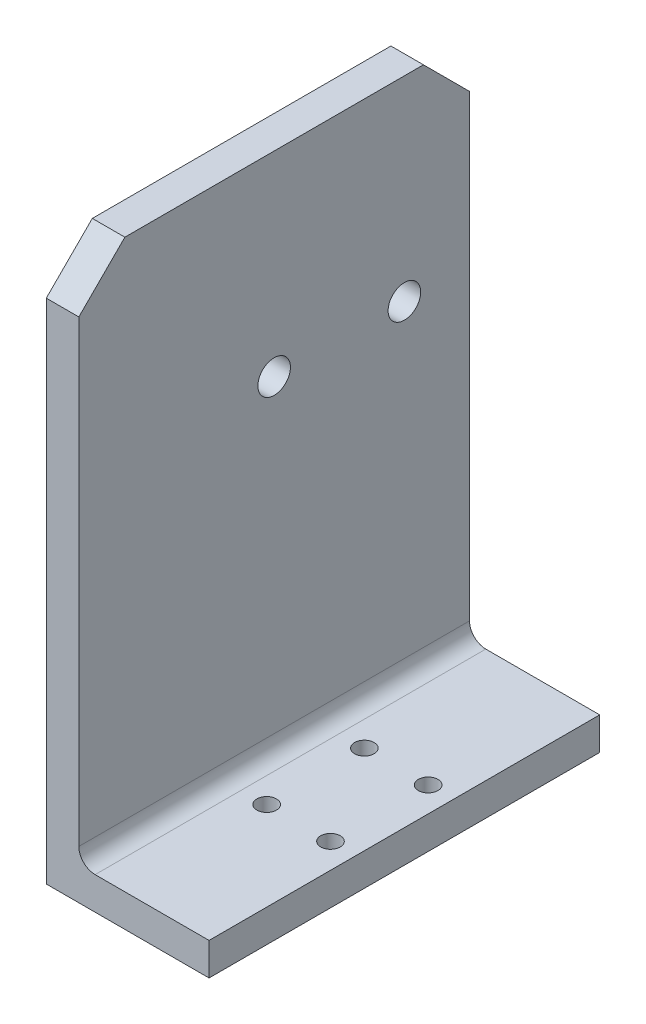
from build123d import *

# Parameters (mm, degrees)
SKETCH1_W             = 25
SKETCH1_H             = 60
BOSS_EXTRUDE1_DEPTH   = 5
SKETCH8_W             = 5
SKETCH8_H             = 60
BOSS_EXTRUDE2_DEPTH   = 80
SKETCH9_R             = 2.5
CUT_EXTRUDE1_DEPTH    = 5
CUT_EXTRUDE2_REACH    = 7
FILLET1_R             = 2.5
F_3_0MM_DOWEL_HOLE2_D = 3
SKETCH15_R            = 2.5
CUT_EXTRUDE3_DEPTH    = 6


with BuildPart() as part:
    # Sketch1 → Boss-Extrude1 (new body)
    with BuildSketch(Plane(origin=(0, 0, 0), x_dir=(1, 0, 0), z_dir=(0, 1, 0))):
        Rectangle(SKETCH1_W, SKETCH1_H)
    extrude(amount=BOSS_EXTRUDE1_DEPTH)

    # Sketch8 → Boss-Extrude2 (add)
    with BuildSketch(Plane(origin=(0, 5, 0), x_dir=(1, 0, 0), z_dir=(0, 1, 0))):
        with Locations((-10, 0)):
            Rectangle(SKETCH8_W, SKETCH8_H)
    extrude(amount=BOSS_EXTRUDE2_DEPTH)

    # Sketch9 → Cut-Extrude1 (cut)
    with BuildSketch(Plane(origin=(-7.5, 0, 0), x_dir=(0, 0, -1), z_dir=(1, 0, 0))):
        with Locations((0, 55)):
            Circle(SKETCH9_R)
    extrude(amount=-CUT_EXTRUDE1_DEPTH, mode=Mode.SUBTRACT)

    # Sketch10 → Cut-Extrude2 (cut, up to next)
    with BuildSketch(Plane(origin=(-7.5, 0, 0), x_dir=(0, 0, -1), z_dir=(1, 0, 0)), mode=Mode.PRIVATE) as cut_extrude2_sk1:
        Polygon((-30, 77.928932188), (-22.928932188, 85), (-30, 85), align=None)
    cut_extrude2_tool1 = extrude(cut_extrude2_sk1.sketch, amount=-CUT_EXTRUDE2_REACH, mode=Mode.PRIVATE) & part.part
    add(cut_extrude2_tool1.solids().sort_by_distance((-7.5, 82.642977, 27.642977))[0], mode=Mode.SUBTRACT)
    # Sketch10 → Cut-Extrude2 (cut, up to next)
    with BuildSketch(Plane(origin=(-7.5, 0, 0), x_dir=(0, 0, -1), z_dir=(1, 0, 0)), mode=Mode.PRIVATE) as cut_extrude2_sk2:
        Polygon((22.928932188, 85), (30, 77.928932188), (30, 85), align=None)
    cut_extrude2_tool2 = extrude(cut_extrude2_sk2.sketch, amount=-CUT_EXTRUDE2_REACH, mode=Mode.PRIVATE) & part.part
    add(cut_extrude2_tool2.solids().sort_by_distance((-7.5, 82.642977, -27.642977))[0], mode=Mode.SUBTRACT)

    # Fillet1
    fillet1_edges = [part.edges().sort_by_distance(p)[0] for p in [
        (-7.5, 5, 0),
    ]]
    fillet(fillet1_edges, radius=FILLET1_R)

    # Ø3.0mm Dowel Hole2 (through all)
    with Locations(Plane(origin=(0, 5, 0), x_dir=(1, 0, 0), z_dir=(0, 1, 0))):
        with Locations((-1.15, -7.5), (-1.15, 7.5)):
            f_3_0mm_dowel_hole2 = Hole(F_3_0MM_DOWEL_HOLE2_D / 2)

    # Mirror1: Ø3.0mm Dowel Hole2 across plane
    add(f_3_0mm_dowel_hole2.mirror(Plane(origin=(3.75, 0, 0), x_dir=(0, 0, 1), z_dir=(1, 0, 0))), mode=Mode.SUBTRACT)

    # Sketch15 → Cut-Extrude3 (cut, through all)
    with BuildSketch(Plane(origin=(-7.5, 0, 0), x_dir=(0, 0, -1), z_dir=(1, 0, 0))):
        with Locations((20, 55)):
            Circle(SKETCH15_R)
    extrude(amount=-CUT_EXTRUDE3_DEPTH, mode=Mode.SUBTRACT)


solid = part.part
